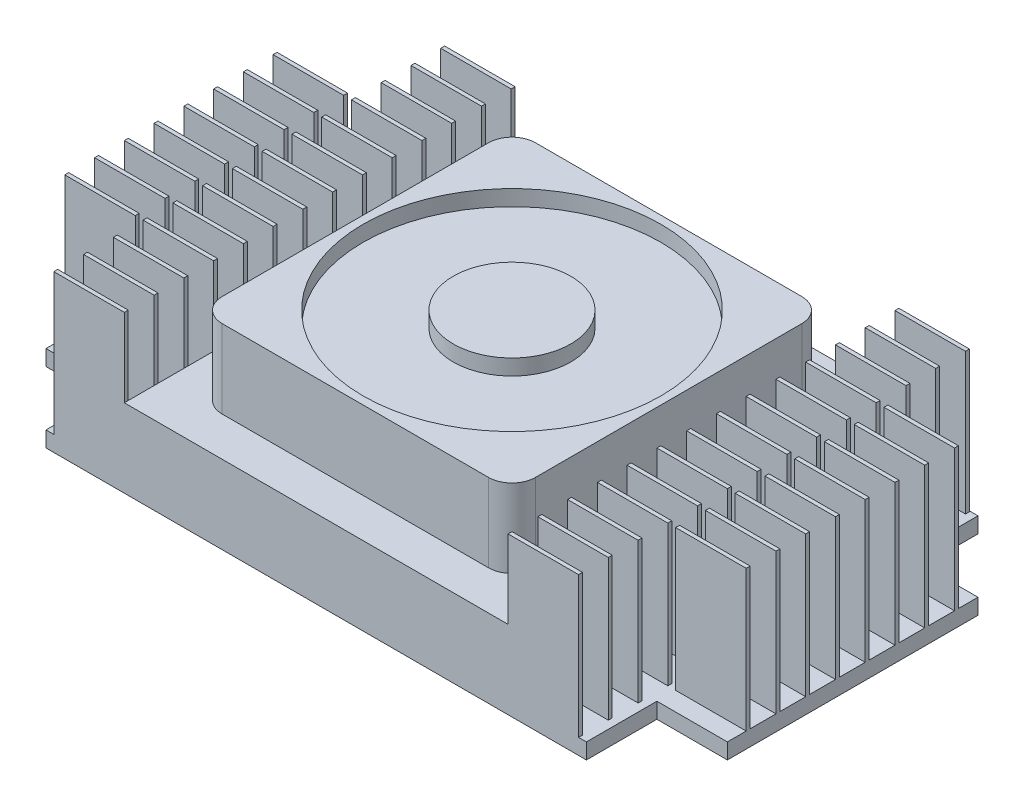
from build123d import *

# Parameters (mm, degrees)
BOSS_EXTRUDE1_DEPTH = 2
SKETCH2_W           = 9
SKETCH2_H           = 0.5
BOSS_EXTRUDE2_DEPTH = 18
SKETCH3_W           = 49
SKETCH3_H           = 50
BOSS_EXTRUDE3_DEPTH = 8
SKETCH4_W           = 40
SKETCH4_H           = 40
BOSS_EXTRUDE4_DEPTH = 10
FILLET1_R           = 3
SKETCH5_R           = 19
SKETCH5_R_2         = 7.5
CUT_EXTRUDE1_DEPTH  = 2


with BuildPart() as part:
    # Sketch1 → Boss-Extrude1 (new body)
    with BuildSketch(Plane(origin=(0, 0, 0), x_dir=(1, 0, 0), z_dir=(0, 1, 0))):
        Polygon((-43.5, 16), (-34.5, 16), (-34.5, 25), (34.5, 25), (34.5, 16), (43.5, 16), (43.5, -16), (34.5, -16), (34.5, -25), (-34.5, -25), (-34.5, -16), (-43.5, -16), align=None)
    extrude(amount=BOSS_EXTRUDE1_DEPTH)

    # Sketch2 → Boss-Extrude2 (add)
    with BuildSketch(Plane(origin=(0, 2, 0), x_dir=(1, 0, 0), z_dir=(0, 1, 0))):
        with Locations((-29, -20.95)):
            Rectangle(SKETCH2_W, SKETCH2_H)
        with Locations((-29, -24.75)):
            Rectangle(SKETCH2_W, SKETCH2_H)
        with Locations((-29, -17.15)):
            Rectangle(SKETCH2_W, SKETCH2_H)
        with Locations((-29, -13.35)):
            Rectangle(SKETCH2_W, SKETCH2_H)
        with Locations((-29, -9.55)):
            Rectangle(SKETCH2_W, SKETCH2_H)
        with Locations((-29, -5.75)):
            Rectangle(SKETCH2_W, SKETCH2_H)
        with Locations((-29, -1.95)):
            Rectangle(SKETCH2_W, SKETCH2_H)
        with Locations((-29, 1.85)):
            Rectangle(SKETCH2_W, SKETCH2_H)
        with Locations((-29, 5.65)):
            Rectangle(SKETCH2_W, SKETCH2_H)
        with Locations((-29, 9.45)):
            Rectangle(SKETCH2_W, SKETCH2_H)
        with Locations((-29, 13.25)):
            Rectangle(SKETCH2_W, SKETCH2_H)
        with Locations((-29, 17.05)):
            Rectangle(SKETCH2_W, SKETCH2_H)
        with Locations((-29, 20.85)):
            Rectangle(SKETCH2_W, SKETCH2_H)
        with Locations((-29, 24.65)):
            Rectangle(SKETCH2_W, SKETCH2_H)
        with Locations((-39, -13.35)):
            Rectangle(SKETCH2_W, SKETCH2_H)
        with Locations((-39, -9.55)):
            Rectangle(SKETCH2_W, SKETCH2_H)
        with Locations((-39, -5.75)):
            Rectangle(SKETCH2_W, SKETCH2_H)
        with Locations((-39, -1.95)):
            Rectangle(SKETCH2_W, SKETCH2_H)
        with Locations((-39, 1.85)):
            Rectangle(SKETCH2_W, SKETCH2_H)
        with Locations((-39, 5.65)):
            Rectangle(SKETCH2_W, SKETCH2_H)
        with Locations((-39, 9.45)):
            Rectangle(SKETCH2_W, SKETCH2_H)
        with Locations((-39, 13.25)):
            Rectangle(SKETCH2_W, SKETCH2_H)
        with Locations((39, 13.25)):
            Rectangle(SKETCH2_W, SKETCH2_H)
        with Locations((39, 9.45)):
            Rectangle(SKETCH2_W, SKETCH2_H)
        with Locations((39, 5.65)):
            Rectangle(SKETCH2_W, SKETCH2_H)
        with Locations((39, 1.85)):
            Rectangle(SKETCH2_W, SKETCH2_H)
        with Locations((39, -1.95)):
            Rectangle(SKETCH2_W, SKETCH2_H)
        with Locations((39, -5.75)):
            Rectangle(SKETCH2_W, SKETCH2_H)
        with Locations((39, -9.55)):
            Rectangle(SKETCH2_W, SKETCH2_H)
        with Locations((39, -13.35)):
            Rectangle(SKETCH2_W, SKETCH2_H)
        with Locations((29, 24.65)):
            Rectangle(SKETCH2_W, SKETCH2_H)
        with Locations((29, 20.85)):
            Rectangle(SKETCH2_W, SKETCH2_H)
        with Locations((29, 17.05)):
            Rectangle(SKETCH2_W, SKETCH2_H)
        with Locations((29, 13.25)):
            Rectangle(SKETCH2_W, SKETCH2_H)
        with Locations((29, 9.45)):
            Rectangle(SKETCH2_W, SKETCH2_H)
        with Locations((29, 5.65)):
            Rectangle(SKETCH2_W, SKETCH2_H)
        with Locations((29, 1.85)):
            Rectangle(SKETCH2_W, SKETCH2_H)
        with Locations((29, -1.95)):
            Rectangle(SKETCH2_W, SKETCH2_H)
        with Locations((29, -5.75)):
            Rectangle(SKETCH2_W, SKETCH2_H)
        with Locations((29, -9.55)):
            Rectangle(SKETCH2_W, SKETCH2_H)
        with Locations((29, -13.35)):
            Rectangle(SKETCH2_W, SKETCH2_H)
        with Locations((29, -17.15)):
            Rectangle(SKETCH2_W, SKETCH2_H)
        with Locations((29, -20.95)):
            Rectangle(SKETCH2_W, SKETCH2_H)
        with Locations((29, -24.75)):
            Rectangle(SKETCH2_W, SKETCH2_H)
    extrude(amount=BOSS_EXTRUDE2_DEPTH)

    # Sketch3 → Boss-Extrude3 (add)
    with BuildSketch(Plane(origin=(0, 2, 0), x_dir=(1, 0, 0), z_dir=(0, 1, 0))):
        Rectangle(SKETCH3_W, SKETCH3_H)
    extrude(amount=BOSS_EXTRUDE3_DEPTH)

    # Sketch4 → Boss-Extrude4 (add)
    with BuildSketch(Plane(origin=(0, 10, 0), x_dir=(1, 0, 0), z_dir=(0, 1, 0))):
        Rectangle(SKETCH4_W, SKETCH4_H)
    extrude(amount=BOSS_EXTRUDE4_DEPTH)

    # Fillet1
    fillet1_edges = [part.edges().sort_by_distance(p)[0] for p in [
        (-20, 15, -20),
        (-20, 15, 20),
        (20, 15, 20),
        (20, 15, -20),
    ]]
    fillet(fillet1_edges, radius=FILLET1_R)

    # Sketch5 → Cut-Extrude1 (cut)
    with BuildSketch(Plane(origin=(0, 20, 0), x_dir=(1, 0, 0), z_dir=(0, 1, 0))):
        Circle(SKETCH5_R)
        Circle(SKETCH5_R_2, mode=Mode.SUBTRACT)
    extrude(amount=-CUT_EXTRUDE1_DEPTH, mode=Mode.SUBTRACT)


solid = part.part
